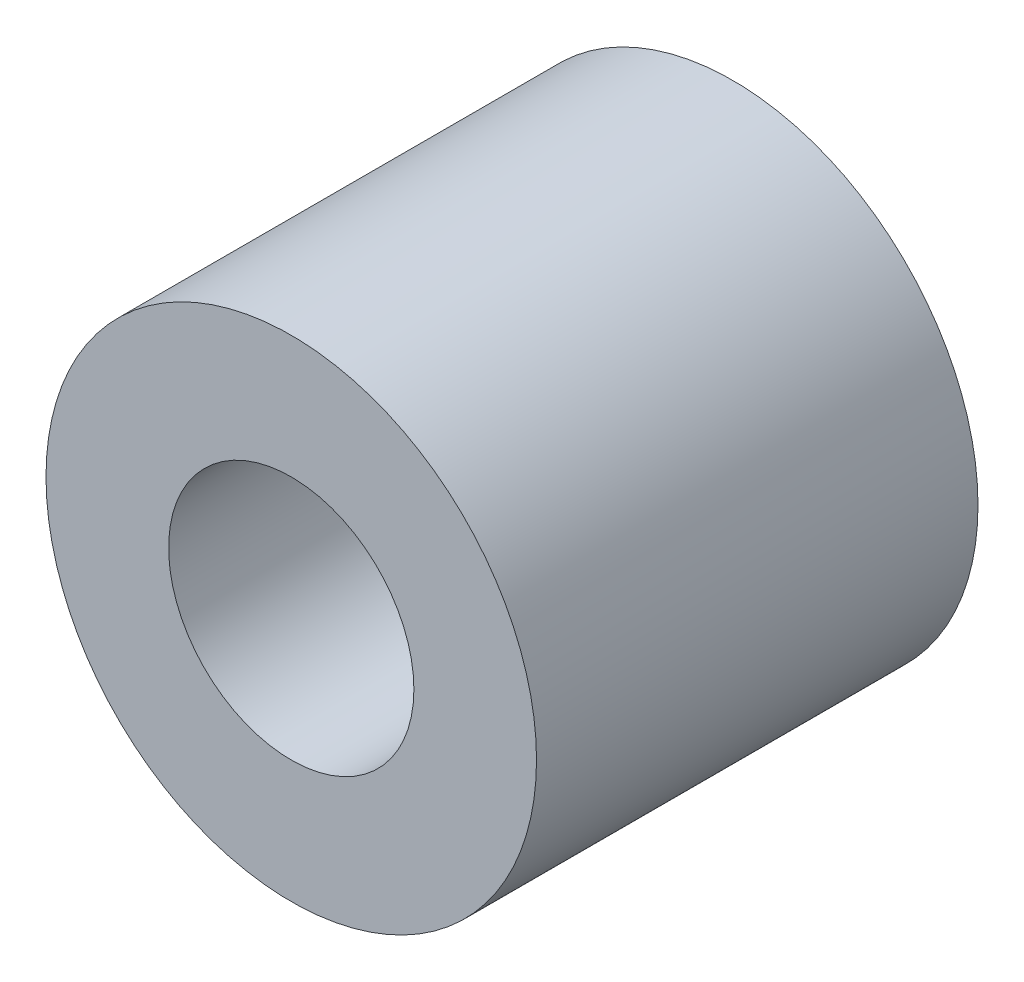
from build123d import *

# Parameters (mm, degrees)
ESQUISSE1_R             = 5
BOSS_EXTRU_1_DEPTH      = 9
ESQUISSE2_R             = 2.5
ENL_V_MAT_EXTRU_1_DEPTH = 13


with BuildPart() as part:
    # Esquisse1 → Boss.-Extru.1 (new body)
    with BuildSketch(Plane.XY):
        Circle(ESQUISSE1_R)
    extrude(amount=BOSS_EXTRU_1_DEPTH)

    # Esquisse2 → Enlèv. mat.-Extru.1 (cut)
    with BuildSketch(Plane.XY.offset(9)):
        Circle(ESQUISSE2_R)
    extrude(amount=-ENL_V_MAT_EXTRU_1_DEPTH, mode=Mode.SUBTRACT)


solid = part.part
